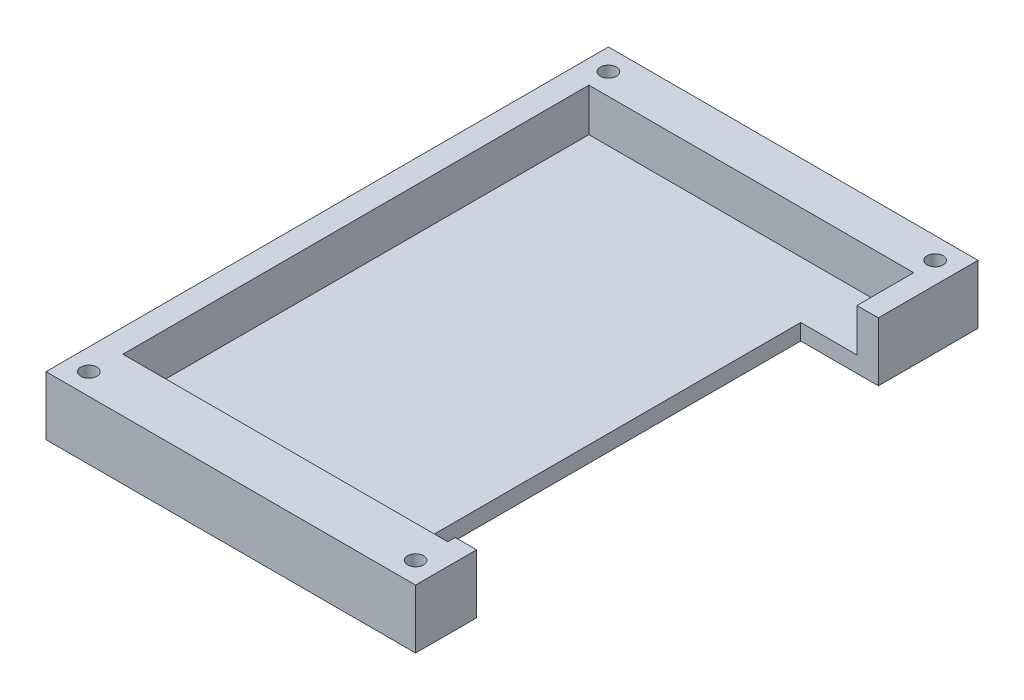
from build123d import *

# Parameters (mm, degrees)
SKETCH1_W           = 69
SKETCH1_H           = 105
BOSS_EXTRUDE2_DEPTH = 11
SKETCH3_W           = 60.642005931
SKETCH3_H           = 87
CUT_EXTRUDE1_DEPTH  = 8
SKETCH4_R           = 1.5
CUT_EXTRUDE2_DEPTH  = 12
SKETCH5_W           = 14.5
SKETCH5_H           = 75
CUT_EXTRUDE3_DEPTH  = 12


with BuildPart() as part:
    # Sketch1 → Boss-Extrude2 (new body)
    with BuildSketch(Plane(origin=(0, 0, 0), x_dir=(1, 0, 0), z_dir=(0, 1, 0))):
        with Locations((34.5, 52.5)):
            Rectangle(SKETCH1_W, SKETCH1_H)
    extrude(amount=BOSS_EXTRUDE2_DEPTH)

    # Sketch3 → Cut-Extrude1 (cut)
    with BuildSketch(Plane(origin=(0, 11, 0), x_dir=(1, 0, 0), z_dir=(0, 1, 0))):
        with Locations((34.678997035, 53.5)):
            Rectangle(SKETCH3_W, SKETCH3_H)
    extrude(amount=-CUT_EXTRUDE1_DEPTH, mode=Mode.SUBTRACT)

    # Sketch4 → Cut-Extrude2 (cut, through all)
    with BuildSketch(Plane(origin=(0, 11, 0), x_dir=(1, 0, 0), z_dir=(0, 1, 0))):
        with Locations((4, 101)):
            Circle(SKETCH4_R)
        with Locations((65, 101)):
            Circle(SKETCH4_R)
        with Locations((4, 4)):
            Circle(SKETCH4_R)
        with Locations((65, 4)):
            Circle(SKETCH4_R)
    extrude(amount=-CUT_EXTRUDE2_DEPTH, mode=Mode.SUBTRACT)

    # Sketch5 → Cut-Extrude3 (cut, through all)
    with BuildSketch(Plane(origin=(0, 11, 0), x_dir=(1, 0, 0), z_dir=(0, 1, 0))):
        with Locations((61.75, 48.9)):
            Rectangle(SKETCH5_W, SKETCH5_H)
    extrude(amount=-CUT_EXTRUDE3_DEPTH, mode=Mode.SUBTRACT)


solid = part.part
